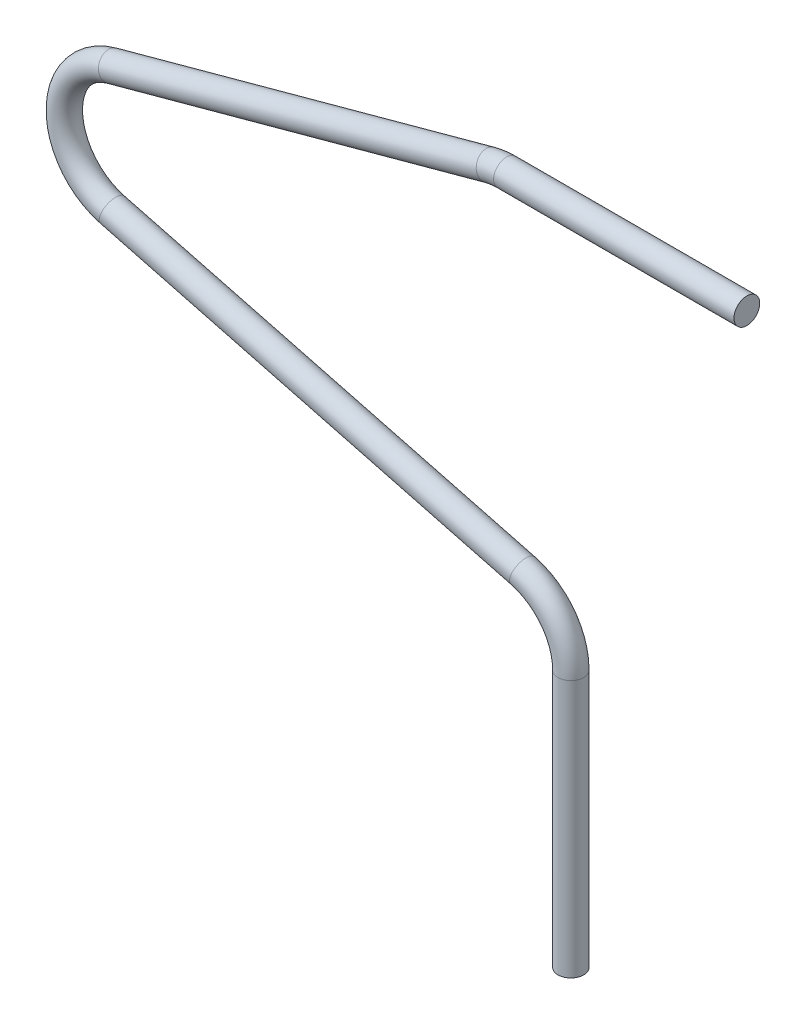
from build123d import *

# Parameters (mm, degrees)
SKIZZE2_R = 0.75


with BuildPart() as part:
    # Austragung1: sweep along a path in Skizze1
    with BuildLine(Plane.XY) as austragung1_path:
        Line((0, 0), (0, 15))
        ThreePointArc((0, 15), (-0.782050775, 17.292111995), (-2.802014612, 18.62819841))
        Line((-2.802014612, 18.62819841), (-26.697985388, 24.87180159))
        ThreePointArc((-26.697985388, 24.87180159), (-29.499946504, 28.47996964), (-26.736690272, 32.11786433))
        Line((-26.736690272, 32.11786433), (-4.736690272, 38.11786433))
        ThreePointArc((-4.736690272, 38.11786433), (-4.247749316, 38.216819288), (-3.75, 38.25))
        Line((-3.75, 38.25), (10.25, 38.25))
    # Skizze2 → Austragung1 (sweep)
    with BuildSketch(Plane(origin=(0, 0, 0), x_dir=(1, 0, 0), z_dir=(0, 1, 0))):
        Circle(SKIZZE2_R)
    sweep(path=austragung1_path.line)


solid = part.part
